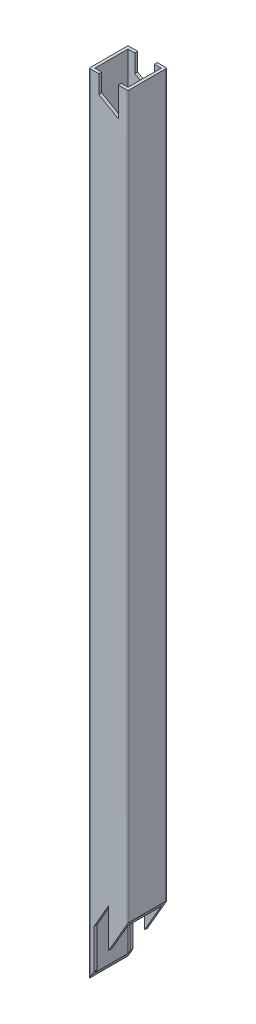
from build123d import *

# Parameters (mm, degrees)
SKETCH1_W           = 17
SKETCH1_H           = 17
BOSS_EXTRUDE1_DEPTH = 405
CUT_EXTRUDE2_DEPTH  = 406.986452976
CUT_EXTRUDE4_DEPTH  = 20
CUT_EXTRUDE5_DEPTH  = 406.986452976


with BuildPart() as part:
    # Sketch1 → Boss-Extrude1 (new body)
    with BuildSketch(Plane(origin=(0, 0, 0), x_dir=(1, 0, 0), z_dir=(0, 1, 0))):
        with BuildLine():
            Line((0.5, 0), (19.5, 0))
            ThreePointArc((19.5, 0), (19.853553391, 0.146446609), (20, 0.5))
            Line((20, 0.5), (20, 19.5))
            ThreePointArc((20, 19.5), (19.853553391, 19.853553391), (19.5, 20))
            Line((19.5, 20), (0.5, 20))
            ThreePointArc((0.5, 20), (0.146446609, 19.853553391), (0, 19.5))
            Line((0, 19.5), (0, 0.5))
            ThreePointArc((0, 0.5), (0.146446609, 0.146446609), (0.5, 0))
        make_face()
        with Locations((10, 10)):
            Rectangle(SKETCH1_W, SKETCH1_H, mode=Mode.SUBTRACT)
    extrude(amount=BOSS_EXTRUDE1_DEPTH)

    # Sketch4 → Cut-Extrude2 (cut, through all)
    with BuildSketch(Plane(origin=(0, 0, -20), x_dir=(-1, 0, 0), z_dir=(0, 0, -1))):
        Polygon((-5, 405), (-5, 395.773502692), (-15, 390), (-15, 405), align=None)
    extrude(amount=-CUT_EXTRUDE2_DEPTH, mode=Mode.SUBTRACT)

    # Sketch2 → Cut-Extrude4 (cut)
    with BuildSketch(Plane.XY):
        Polygon((20, 0), (20, 34.641016151), (0, 0), align=None)
    extrude(amount=-CUT_EXTRUDE4_DEPTH, mode=Mode.SUBTRACT)

    # Sketch6 → Cut-Extrude5 (cut, through all)
    with BuildSketch(Plane(origin=(0, 0, -20), x_dir=(-1, 0, 0), z_dir=(0, 0, -1))):
        Polygon((-2.59, 4.486011592), (-2.59, 24.486011592), (-10.09, 37.476392648), (-10.09, 17.476392648), align=None)
    extrude(amount=-CUT_EXTRUDE5_DEPTH, mode=Mode.SUBTRACT)


solid = part.part
